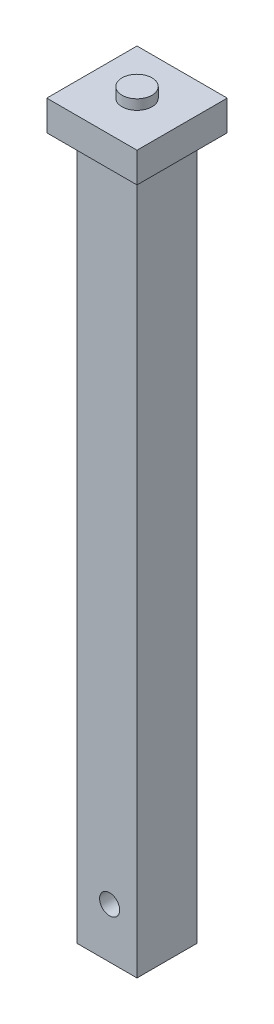
from build123d import *

# Parameters (mm, degrees)
SKETCH1_W           = 90
SKETCH1_H           = 90
BOSS_EXTRUDE1_DEPTH = 30
SKETCH2_W           = 60
SKETCH2_H           = 60
BOSS_EXTRUDE2_DEPTH = 700
SKETCH3_R           = 10
CUT_EXTRUDE1_DEPTH  = 76
SKETCH4_R           = 15
BOSS_EXTRUDE3_DEPTH = 10


with BuildPart() as part:
    # Sketch1 → Boss-Extrude1 (new body)
    with BuildSketch(Plane(origin=(0, 0, 0), x_dir=(1, 0, 0), z_dir=(0, 1, 0))):
        Rectangle(SKETCH1_W, SKETCH1_H)
    extrude(amount=BOSS_EXTRUDE1_DEPTH)

    # Sketch2 → Boss-Extrude2 (add)
    with BuildSketch(Plane.XZ):
        Rectangle(SKETCH2_W, SKETCH2_H)
    extrude(amount=BOSS_EXTRUDE2_DEPTH)

    # Sketch3 → Cut-Extrude1 (cut, through all)
    with BuildSketch(Plane.XY.offset(30)):
        with Locations((2.6929442, -650)):
            Circle(SKETCH3_R)
    extrude(amount=-CUT_EXTRUDE1_DEPTH, mode=Mode.SUBTRACT)

    # Sketch4 → Boss-Extrude3 (add)
    with BuildSketch(Plane(origin=(0, 30, 0), x_dir=(1, 0, 0), z_dir=(0, 1, 0))):
        Circle(SKETCH4_R)
    extrude(amount=BOSS_EXTRUDE3_DEPTH)


solid = part.part
